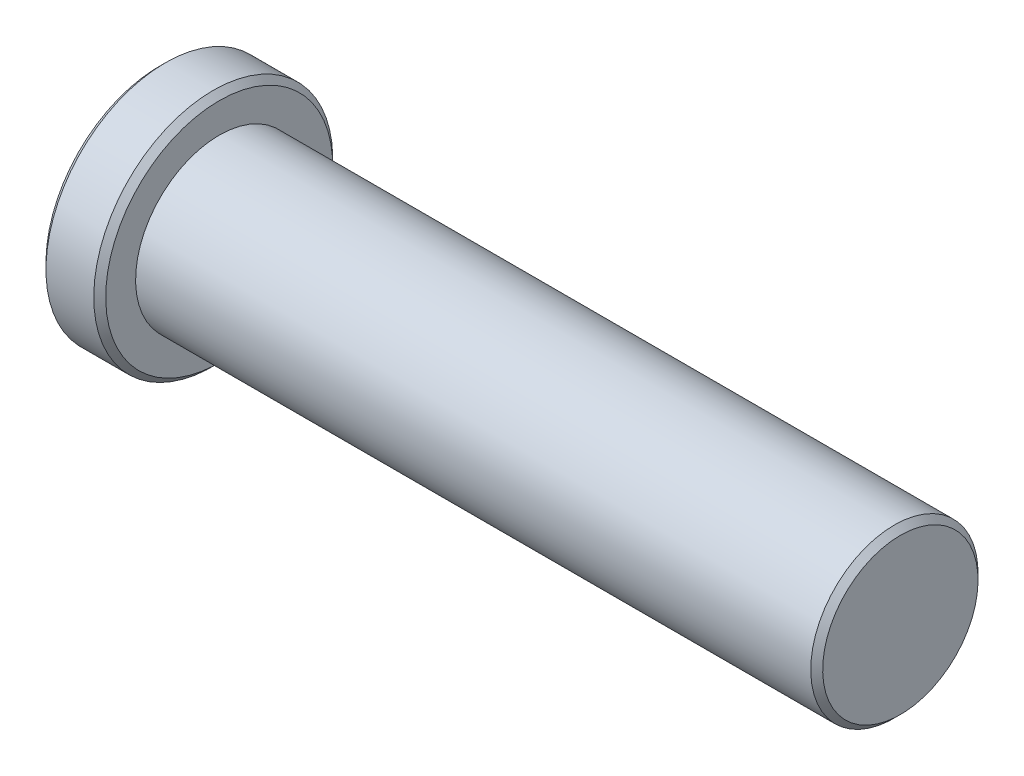
from build123d import *

# Parameters (mm, degrees)
SFAZOWANIE1_SIZE = 0.5


with BuildPart() as part:
    # Szkic1 → Obrót1 (revolve)
    with BuildSketch(Plane.XY):
        Polygon((0, 0), (0, 10), (5, 10), (5, 7), (62, 7), (62, 0), align=None)
    revolve(axis=Axis((62, 0, 0), (-1, 0, 0)))

    # Sfazowanie1
    sfazowanie1_edges = [part.edges().sort_by_distance(p)[0] for p in [
        (62, -7, 0),
        (5, -10, 0),
        (0, -10, 0),
    ]]
    chamfer(sfazowanie1_edges, length=SFAZOWANIE1_SIZE)


solid = part.part
